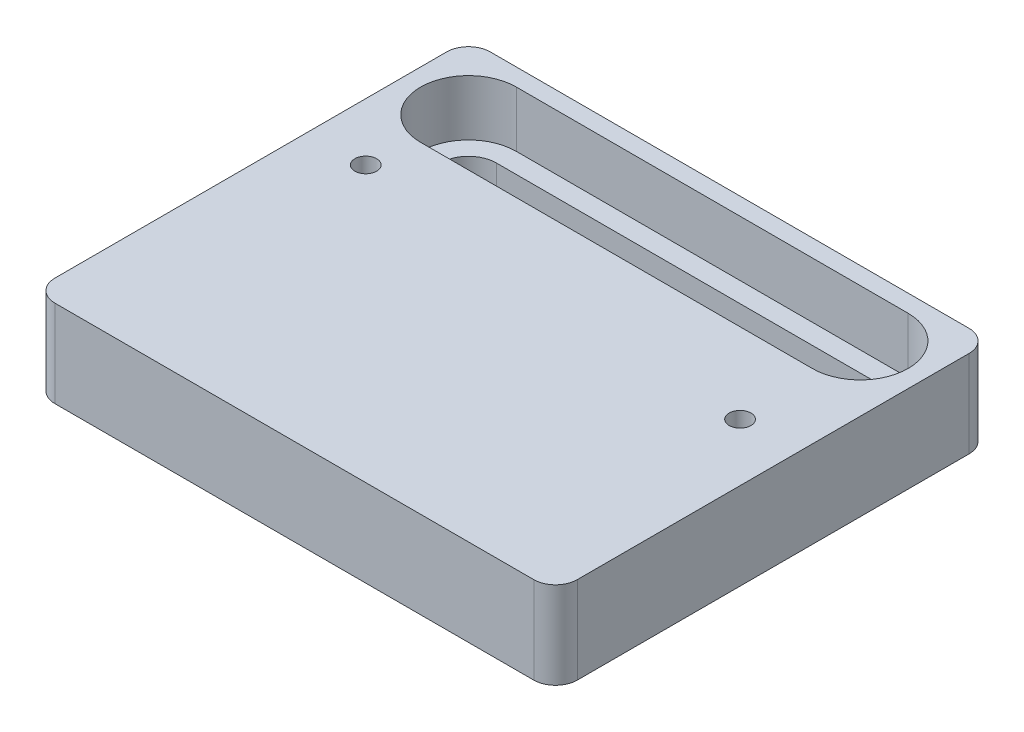
from build123d import *

# Parameters (mm, degrees)
SKETCH1_W             = 60
SKETCH1_H             = 50
BOSS_EXTRUDE1_DEPTH   = 10
M3_TAPPED_HOLE1_D     = 2.5
M3_TAPPED_HOLE1_DEPTH = 10
CUT_EXTRUDE1_DEPTH    = 6.4
CUT_EXTRUDE2_DEPTH    = 4.6
FILLET1_R             = 2.5


with BuildPart() as part:
    # Sketch1 → Boss-Extrude1 (new body)
    with BuildSketch(Plane(origin=(0, 0, 0), x_dir=(1, 0, 0), z_dir=(0, 1, 0))):
        Rectangle(SKETCH1_W, SKETCH1_H)
    extrude(amount=BOSS_EXTRUDE1_DEPTH)

    # M3 Tapped Hole1
    with Locations(Plane(origin=(0, 10, 0), x_dir=(1, 0, 0), z_dir=(0, 1, 0))):
        with Locations((-23.4, 6.6), (23.4, 2.8)):
            Hole(M3_TAPPED_HOLE1_D / 2, depth=M3_TAPPED_HOLE1_DEPTH)

    # Sketch7 → Cut-Extrude1 (cut)
    with BuildSketch(Plane(origin=(0, 10, 0), x_dir=(1, 0, 0), z_dir=(0, 1, 0))):
        with BuildLine():
            Line((-22.5, 23), (22.5, 23))
            ThreePointArc((22.5, 23), (28, 17.5), (22.5, 12))
            Line((22.5, 12), (-22.5, 12))
            ThreePointArc((-22.5, 12), (-28, 17.5), (-22.5, 23))
        make_face()
    extrude(amount=-CUT_EXTRUDE1_DEPTH, mode=Mode.SUBTRACT)

    # Sketch8 → Cut-Extrude2 (cut, through all)
    with BuildSketch(Plane(origin=(0, 3.6, 0), x_dir=(1, 0, 0), z_dir=(0, 1, 0))):
        with BuildLine():
            Line((-22.5, 20.7), (22.5, 20.7))
            ThreePointArc((22.5, 20.7), (25.7, 17.5), (22.5, 14.3))
            Line((22.5, 14.3), (-22.5, 14.3))
            ThreePointArc((-22.5, 14.3), (-25.7, 17.5), (-22.5, 20.7))
        make_face()
    extrude(amount=-CUT_EXTRUDE2_DEPTH, mode=Mode.SUBTRACT)

    # Fillet1
    fillet1_edges = [part.edges().sort_by_distance(p)[0] for p in [
        (30, 5, 25),
        (-30, 5, 25),
        (-30, 5, -25),
        (30, 5, -25),
    ]]
    fillet(fillet1_edges, radius=FILLET1_R)


solid = part.part
